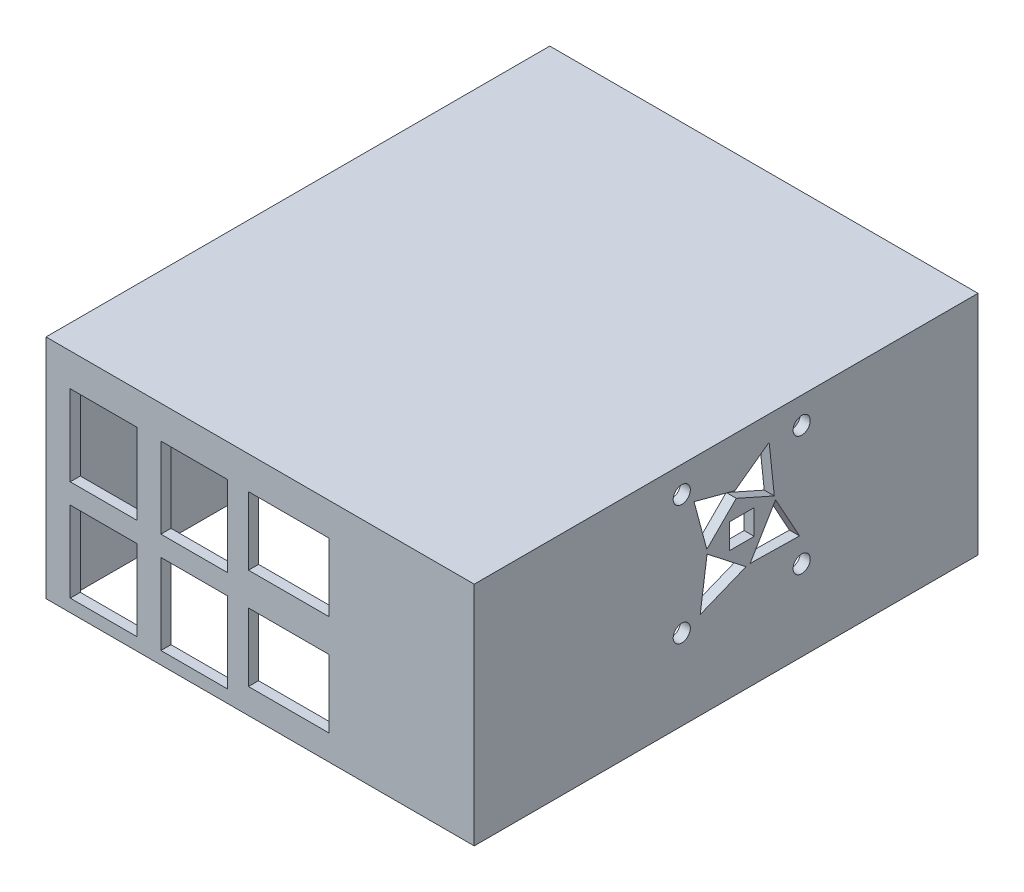
from build123d import *

# Parameters (mm, degrees)
SKETCH1_W           = 85
SKETCH1_H           = 100
BOSS_EXTRUDE1_DEPTH = 45
SHELL1_T            = -2
SKETCH3_R           = 2.5
BOSS_EXTRUDE2_DEPTH = 3
SKETCH4_R           = 1.025
CUT_EXTRUDE1_DEPTH  = 2.7
SKETCH17_W          = 13.25
SKETCH17_H          = 16
SKETCH17_W_2        = 16
SKETCH17_H_2        = 13.5
CUT_EXTRUDE2_DEPTH  = 2
LPATTERN1_COUNT     = 2
LPATTERN1_PITCH     = 20
SKETCH18_R          = 1.7
CUT_EXTRUDE3_DEPTH  = 2
CUT_EXTRUDE9_DEPTH  = 10
CIRPATTERN2_COUNT   = 4
CIRPATTERN2_ANGLE   = 291
SKETCH19_4_W        = 4.949747468
SKETCH19_4_H        = 4.949747468
CUT_EXTRUDE10_DEPTH = 10


with BuildPart() as part:
    # Sketch1 → Boss-Extrude1 (new body)
    with BuildSketch(Plane(origin=(0, 0, 0), x_dir=(1, 0, 0), z_dir=(0, 1, 0))):
        Rectangle(SKETCH1_W, SKETCH1_H)
    extrude(amount=BOSS_EXTRUDE1_DEPTH)

    # Shell1
    shell1_openings = [part.faces().sort_by_distance(p)[0] for p in [
        (0, 0, 0),
    ]]
    offset(amount=SHELL1_T, openings=shell1_openings, kind=Kind.INTERSECTION)

    # Sketch3 → Boss-Extrude2 (add)
    with BuildSketch(Plane.XZ.offset(-43)):
        with Locations((-36.5, 24.5)):
            Circle(SKETCH3_R)
        with Locations((12.5, 24.5)):
            Circle(SKETCH3_R)
        with Locations((-36.5, -33.5)):
            Circle(SKETCH3_R)
        with Locations((12.5, -33.5)):
            Circle(SKETCH3_R)
    extrude(amount=BOSS_EXTRUDE2_DEPTH)

    # Sketch4 → Cut-Extrude1 (cut)
    with BuildSketch(Plane.XZ.offset(-40)):
        with Locations((12.5, 24.5)):
            Circle(SKETCH4_R)
        with Locations((-36.5, 24.5)):
            Circle(SKETCH4_R)
        with Locations((-36.5, -33.5)):
            Circle(SKETCH4_R)
        with Locations((12.5, -33.5)):
            Circle(SKETCH4_R)
    extrude(amount=-CUT_EXTRUDE1_DEPTH, mode=Mode.SUBTRACT)

    # Sketch17 → Cut-Extrude2 (cut)
    with BuildSketch(Plane.XY.offset(50)):
        with Locations((-31.065, 30.5)):
            Rectangle(SKETCH17_W, SKETCH17_H)
        with Locations((-13.065, 30.5)):
            Rectangle(SKETCH17_W, SKETCH17_H)
        with Locations((5.69, 31.75)):
            Rectangle(SKETCH17_W_2, SKETCH17_H_2)
    cut_extrude2 = extrude(amount=-CUT_EXTRUDE2_DEPTH, mode=Mode.SUBTRACT)

    # LPattern1: Cut-Extrude2 ×2
    with Locations(*[(0, -i * LPATTERN1_PITCH, 0) for i in range(1, LPATTERN1_COUNT)]):
        add(cut_extrude2, mode=Mode.SUBTRACT)

    # Sketch18 → Cut-Extrude3 (cut)
    with BuildSketch(Plane(origin=(42.5, 0, 0), x_dir=(0, 0, -1), z_dir=(1, 0, 0))):
        with Locations((15, 16)):
            Circle(SKETCH18_R)
        with Locations((-8.8, 16)):
            Circle(SKETCH18_R)
        with Locations((-8.8, 39.8)):
            Circle(SKETCH18_R)
        with Locations((15, 39.8)):
            Circle(SKETCH18_R)
    extrude(amount=-CUT_EXTRUDE3_DEPTH, mode=Mode.SUBTRACT)

    # Sketch19 → Cut-Extrude9 (cut)
    with BuildSketch(Plane(origin=(42.5, 0, 0), x_dir=(0, 0, -1), z_dir=(1, 0, 0))):
        Polygon((-6.364101615, 37.364101615), (-3.82820323, 27.9), (3.1, 34.82820323), align=None)
    cut_extrude9 = extrude(amount=-CUT_EXTRUDE9_DEPTH, mode=Mode.SUBTRACT)

    # CirPattern2: Cut-Extrude9 ×4 about axis
    cirpattern2_axis = Axis((0, 27.9, -3.1), (1, 0, 0))
    for i in range(1, CIRPATTERN2_COUNT):
        add(cut_extrude9.rotate(cirpattern2_axis, i * CIRPATTERN2_ANGLE / (CIRPATTERN2_COUNT - 1)), mode=Mode.SUBTRACT)

    # Sketch19_4 → Cut-Extrude10 (cut)
    with BuildSketch(Plane(origin=(42.5, 0, 0), x_dir=(0, 0, -1), z_dir=(1, 0, 0))):
        with Locations((3.1, 27.9)):
            Rectangle(SKETCH19_4_W, SKETCH19_4_H)
    extrude(amount=-CUT_EXTRUDE10_DEPTH, mode=Mode.SUBTRACT)


solid = part.part
